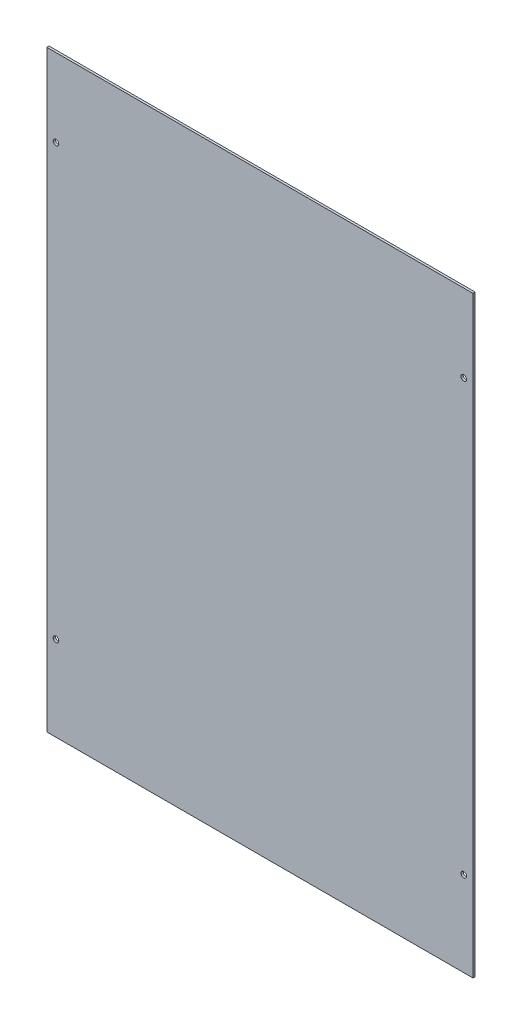
from build123d import *

# Parameters (mm, degrees)
SKETCH1_W           = 584.2
SKETCH1_H           = 812.8
BOSS_EXTRUDE1_DEPTH = 3.0734
SKETCH3_R           = 3.81
CUT_EXTRUDE1_DEPTH  = 4.0734
CUT_EXTRUDE2_DEPTH  = 2.54


with BuildPart() as part:
    # Sketch1 → Boss-Extrude1 (new body)
    with BuildSketch(Plane.XY):
        Rectangle(SKETCH1_W, SKETCH1_H)
    extrude(amount=BOSS_EXTRUDE1_DEPTH)

    # Sketch3 → Cut-Extrude1 (cut, through all)
    with BuildSketch(Plane.XY.offset(3.0734)):
        with Locations((279.5016, 299.72)):
            Circle(SKETCH3_R)
        with Locations((-279.5016, -290.0934)):
            Circle(SKETCH3_R)
        with Locations((279.5016, -290.0934)):
            Circle(SKETCH3_R)
        with Locations((-279.5016, 299.72)):
            Circle(SKETCH3_R)
    extrude(amount=-CUT_EXTRUDE1_DEPTH, mode=Mode.SUBTRACT)

    # Sketch4 → Cut-Extrude2 (cut)
    with BuildSketch(Plane(origin=(0, 0, 0), x_dir=(-1, 0, 0), z_dir=(0, 0, -1))):
        Polygon((-0.508, -393.7), (0.508, -393.7), (0.508, -392.43), (1.016, -392.43), (0, -391.16), (-1.016, -392.43), (-0.508, -392.43), align=None)
    extrude(amount=-CUT_EXTRUDE2_DEPTH, mode=Mode.SUBTRACT)


solid = part.part
